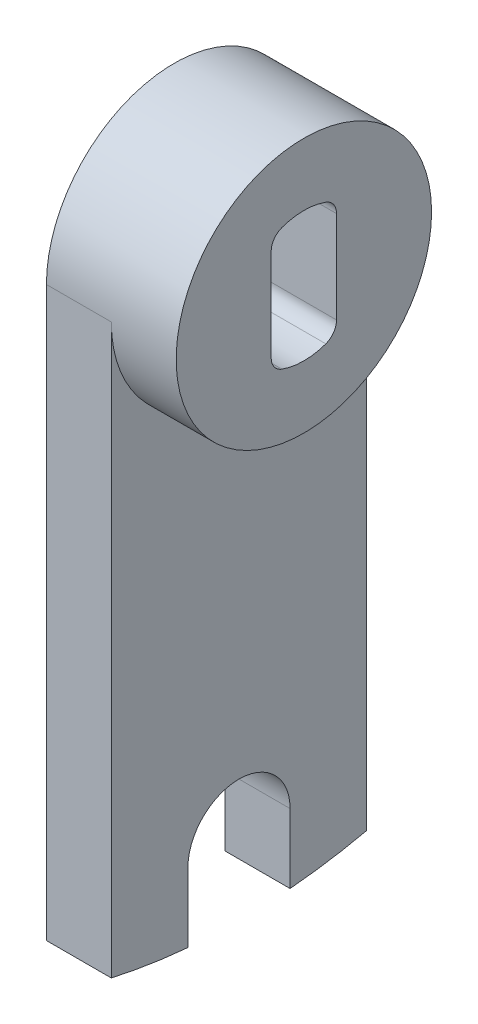
from build123d import *

# Parameters (mm, degrees)
BOSS_EXTRUDE1_DEPTH = 3.175
SKETCH2_R           = 12.5
BOSS_EXTRUDE2_DEPTH = 6.35
FILLET1_R           = 1.5875


with BuildPart() as part:
    # Sketch1 → Boss-Extrude1 (new body, symmetric)
    with BuildSketch(Plane(origin=(0, 0, 0), x_dir=(0, 0, -1), z_dir=(1, 0, 0))):
        with BuildLine():
            Line((12.5, 0), (12.5, -55.612498595))
            ThreePointArc((12.5, -55.612498595), (8.769459923, -56.321368704), (5, -56.780278266))
            Line((5, -56.780278266), (5, -50))
            ThreePointArc((5, -50), (0, -45), (-5, -50))
            Line((-5, -50), (-5, -56.780278266))
            ThreePointArc((-5, -56.780278266), (-8.769459923, -56.321368704), (-12.5, -55.612498595))
            Line((-12.5, -55.612498595), (-12.5, 0))
            ThreePointArc((-12.5, 0), (0, 12.5), (12.5, 0))
        make_face()
        with BuildLine():
            Line((-3.2004, 5.51390651), (-3.2004, -5.51390651))
            ThreePointArc((-3.2004, -5.51390651), (0, -6.3754), (3.2004, -5.51390651))
            Line((3.2004, -5.51390651), (3.2004, 5.51390651))
            ThreePointArc((3.2004, 5.51390651), (0, 6.3754), (-3.2004, 5.51390651))
        make_face(mode=Mode.SUBTRACT)
    extrude(amount=BOSS_EXTRUDE1_DEPTH, both=True)

    # Sketch2 → Boss-Extrude2 (add)
    with BuildSketch(Plane(origin=(3.175, 0, 0), x_dir=(0, 0, -1), z_dir=(1, 0, 0))):
        Circle(SKETCH2_R)
        with BuildLine():
            Line((-3.2004, 5.51390651), (-3.2004, -5.51390651))
            ThreePointArc((-3.2004, -5.51390651), (0, -6.3754), (3.2004, -5.51390651))
            Line((3.2004, -5.51390651), (3.2004, 5.51390651))
            ThreePointArc((3.2004, 5.51390651), (0, 6.3754), (-3.2004, 5.51390651))
        make_face(mode=Mode.SUBTRACT)
    extrude(amount=BOSS_EXTRUDE2_DEPTH)

    # Fillet1
    fillet1_edges = [part.edges().sort_by_distance(p)[0] for p in [
        (0, 5.51390651, -3.2004),
        (0, 5.51390651, 3.2004),
        (0, -5.51390651, 3.2004),
        (0, -5.51390651, -3.2004),
    ]]
    fillet(fillet1_edges, radius=FILLET1_R)


solid = part.part
